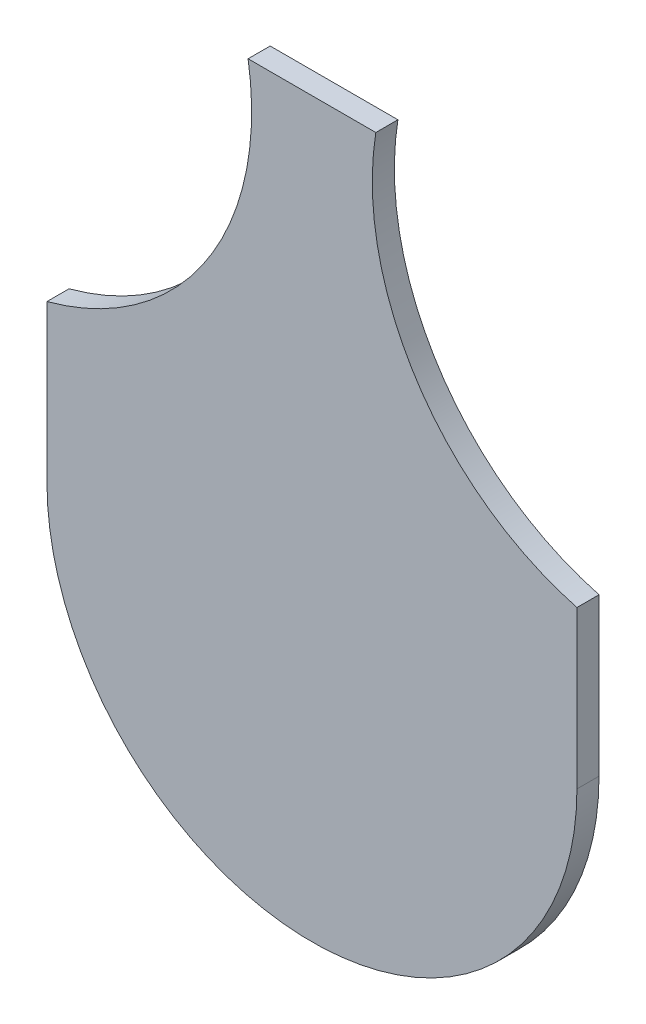
from build123d import *

# Parameters (mm, degrees)
BOSS_EXTRUDE1_DEPTH = 5


with BuildPart() as part:
    # Sketch7 → Boss-Extrude1 (new body)
    with BuildSketch(Plane.XY):
        with BuildLine():
            Line((-60, 0), (-60, 35.574471566))
            ThreePointArc((-60, 35.574471566), (-23.683853056, 61.996329512), (-14.461827551, 105.950070556))
            Line((-14.461827551, 105.950070556), (14.461827551, 105.950070556))
            ThreePointArc((14.461827551, 105.950070556), (23.683853056, 61.996329512), (60, 35.574471566))
            Line((60, 35.574471566), (60, 0))
            ThreePointArc((60, 0), (0, -60), (-60, 0))
        make_face()
    extrude(amount=BOSS_EXTRUDE1_DEPTH)


solid = part.part
